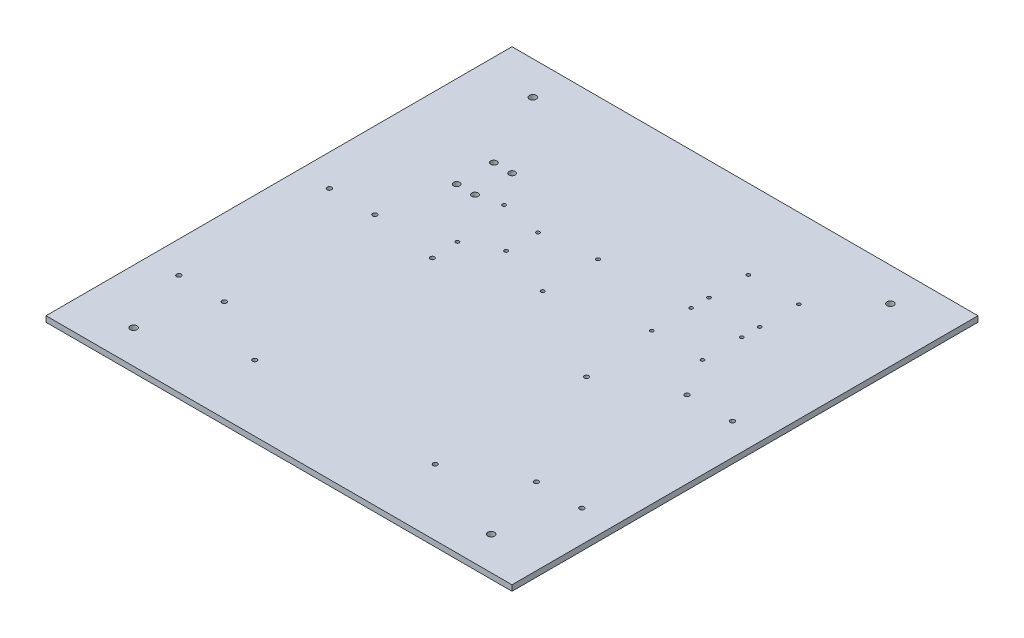
from build123d import *

# Parameters (mm, degrees)
SKETCH_1_W             = 410
SKETCH_1_H             = 410
EXTRUDE_1_DEPTH        = 5
SKETCH_2_R             = 3
CUT_EXTRUDE_4_DEPTH    = 5
SKETCH_5_R             = 1.9
TX2_DEPTH              = 5
SKETCH_6_R             = 1.562
ARDUINOMEGA_DEPTH      = 10
SKETCH_9_R             = 1.5
H_BRIDGE_DEPTH         = 10
SKETCH_10_R            = 2.75
CUT_EXTRUDE_4767_DEPTH = 10
SKETCH_4811_R          = 2
CUT_EXTRUDE_4_2_DEPTH  = 10


with BuildPart() as part:
    # 草圖1 → 填料-伸長1 (new body)
    with BuildSketch(Plane(origin=(0, 0, 0), x_dir=(1, 0, 0), z_dir=(0, 1, 0))):
        Rectangle(SKETCH_1_W, SKETCH_1_H)
    extrude(amount=EXTRUDE_1_DEPTH)

    # 草圖2 → Cut-Extrude 4 (cut)
    with BuildSketch(Plane(origin=(0, 5, 0), x_dir=(1, 0, 0), z_dir=(0, 1, 0))):
        with Locations((-157.3, 175.6)):
            Circle(SKETCH_2_R)
        with Locations((157.3, 175.6)):
            Circle(SKETCH_2_R)
        with Locations((-157.3, -175.6)):
            Circle(SKETCH_2_R)
        with Locations((157.3, -175.6)):
            Circle(SKETCH_2_R)
    extrude(amount=-CUT_EXTRUDE_4_DEPTH, mode=Mode.SUBTRACT)

    # 草圖5 → TX2 (cut)
    with BuildSketch(Plane(origin=(0, 5, 0), x_dir=(1, 0, 0), z_dir=(0, 1, 0))):
        with Locations((-79, 8.968009282)):
            Circle(SKETCH_5_R)
        with Locations((79.4, -13.831990718)):
            Circle(SKETCH_5_R)
        with Locations((-79.4, -146.931990718)):
            Circle(SKETCH_5_R)
        with Locations((79.4, -146.931990718)):
            Circle(SKETCH_5_R)
    extrude(amount=-TX2_DEPTH, mode=Mode.SUBTRACT)

    # 草圖6 → ArduinoMega螺絲孔 (cut)
    with BuildSketch(Plane(origin=(0, 5, 0), x_dir=(1, 0, 0), z_dir=(0, 1, 0))):
        with Locations((-80.353898009, 32.251873694)):
            Circle(SKETCH_6_R)
        with Locations((-87.846898009, 80.871873694)):
            Circle(SKETCH_6_R)
        with Locations((-51.994898009, 74.827873694)):
            Circle(SKETCH_6_R)
        with Locations((-51.994898009, 46.811873694)):
            Circle(SKETCH_6_R)
        with Locations((-5.220898009, 80.871873694)):
            Circle(SKETCH_6_R)
        with Locations((-5.220898009, 32.251873694)):
            Circle(SKETCH_6_R)
    extrude(amount=-ARDUINOMEGA_DEPTH, mode=Mode.SUBTRACT)

    # 草圖9 → H bridge 螺絲孔 (cut)
    with BuildSketch(Plane(origin=(0, 5, 0), x_dir=(1, 0, 0), z_dir=(0, 1, 0))):
        with Locations((72.884226585, 135.005408198)):
            Circle(SKETCH_9_R)
        with Locations((117.484226585, 135.005408198)):
            Circle(SKETCH_9_R)
        with Locations((72.884226585, 100.405408198)):
            Circle(SKETCH_9_R)
        with Locations((117.484226585, 100.405408198)):
            Circle(SKETCH_9_R)
        with Locations((72.884226585, 84.72238538)):
            Circle(SKETCH_9_R)
        with Locations((72.884226585, 50.12238538)):
            Circle(SKETCH_9_R)
        with Locations((117.484226585, 84.72238538)):
            Circle(SKETCH_9_R)
        with Locations((117.484226585, 50.12238538)):
            Circle(SKETCH_9_R)
    extrude(amount=-H_BRIDGE_DEPTH, mode=Mode.SUBTRACT)

    # 草圖10 → Cut-Extrude 4767 (cut)
    with BuildSketch(Plane(origin=(0, 5, 0), x_dir=(1, 0, 0), z_dir=(0, 1, 0))):
        with Locations((-124.601837455, 108.626671886)):
            Circle(SKETCH_10_R)
        with Locations((-108.501837455, 108.626671886)):
            Circle(SKETCH_10_R)
        with Locations((-124.601837455, 75.926671886)):
            Circle(SKETCH_10_R)
        with Locations((-108.501837455, 75.926671886)):
            Circle(SKETCH_10_R)
    extrude(amount=-CUT_EXTRUDE_4767_DEPTH, mode=Mode.SUBTRACT)

    # Sketch 4811 → Cut-Extrude 4 2 (cut)
    with BuildSketch(Plane(origin=(0, 5, 0), x_dir=(1, 0, 0), z_dir=(0, 1, 0))):
        with Locations((-137.3, 16.663672704)):
            Circle(SKETCH_4811_R)
        with Locations((-177.3, 16.663672704)):
            Circle(SKETCH_4811_R)
        with Locations((-177.3, -115.836327296)):
            Circle(SKETCH_4811_R)
        with Locations((-137.3, -115.836327296)):
            Circle(SKETCH_4811_R)
        with Locations((137.3, 16.663672704)):
            Circle(SKETCH_4811_R)
        with Locations((177.3, 16.663672704)):
            Circle(SKETCH_4811_R)
        with Locations((137.3, -115.836327296)):
            Circle(SKETCH_4811_R)
        with Locations((177.3, -115.836327296)):
            Circle(SKETCH_4811_R)
    extrude(amount=-CUT_EXTRUDE_4_2_DEPTH, mode=Mode.SUBTRACT)


solid = part.part
